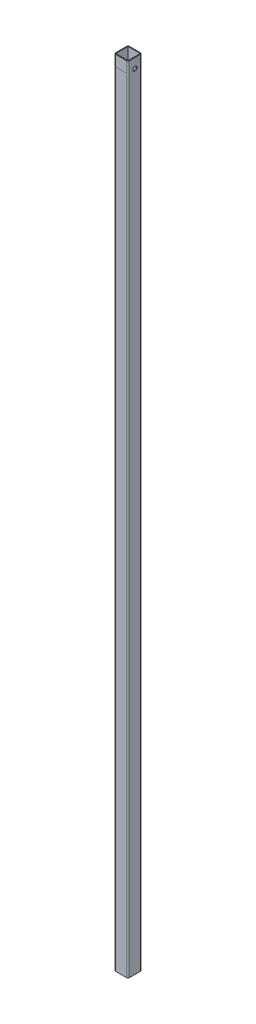
from build123d import *

# Parameters (mm, degrees)
SKETCH1_W                   = 22.8092
SKETCH1_H                   = 22.8092
SKETCH1_W_2                 = 20.1422
SKETCH1_H_2                 = 20.1422
BOSS_EXTRUDE1_DEPTH         = 1303.02
FILLET1_R                   = 2.54
F_1_4_0_25_DIAMETER_HOLE1_D = 6.35
F_1_4_CLEARANCE_HOLE1_D     = 6.7564


with BuildPart() as part:
    # Sketch1 → Boss-Extrude1 (new body)
    with BuildSketch(Plane(origin=(0, 0, 0), x_dir=(1, 0, 0), z_dir=(0, 1, 0))):
        Rectangle(SKETCH1_W, SKETCH1_H)
        Rectangle(SKETCH1_W_2, SKETCH1_H_2, mode=Mode.SUBTRACT)
    extrude(amount=BOSS_EXTRUDE1_DEPTH)

    # Fillet1
    fillet1_edges = [part.edges().sort_by_distance(p)[0] for p in [
        (11.4046, 651.51, 11.4046),
        (-11.4046, 651.51, 11.4046),
        (-11.4046, 651.51, -11.4046),
        (11.4046, 651.51, -11.4046),
    ]]
    fillet(fillet1_edges, radius=FILLET1_R)

    # 1/4 (0.25) Diameter Hole1 (through all)
    with Locations(Plane(origin=(0, 0, 0), x_dir=(-1, 0, 0), z_dir=(0, -1, 0))):
        with Locations((0, 0)):
            Hole(F_1_4_0_25_DIAMETER_HOLE1_D / 2)

    # 1/4 Clearance Hole1 (through all)
    with Locations(Plane(origin=(11.4046, 0, 0), x_dir=(0, 0, -1), z_dir=(1, 0, 0))):
        with Locations((0, 1287.145)):
            Hole(F_1_4_CLEARANCE_HOLE1_D / 2)


solid = part.part
